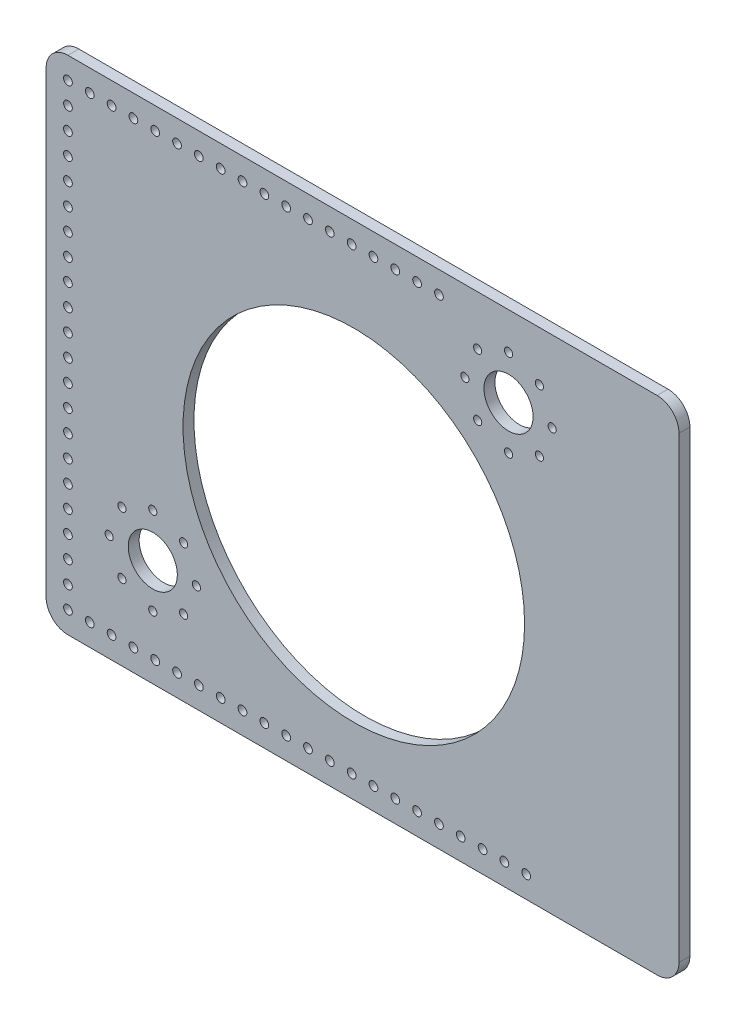
from build123d import *

# Parameters (mm, degrees)
SKETCH1_W           = 368.3
SKETCH1_H           = 292.1
SKETCH1_R           = 99.3775
SKETCH1_R_2         = 2.54
BOSS_EXTRUDE1_DEPTH = 6.35
SKETCH2_R           = 14.2875
SKETCH2_R_2         = 2.38125
CUT_EXTRUDE1_DEPTH  = 7.35
FILLET1_R           = 12.7


with BuildPart() as part:
    # Sketch1 → Boss-Extrude1 (new body)
    with BuildSketch(Plane.XY):
        with Locations((184.15, 146.05)):
            Rectangle(SKETCH1_W, SKETCH1_H)
        with Locations((179.07, 138.43)):
            Circle(SKETCH1_R, mode=Mode.SUBTRACT)
        with Locations((12.7, 279.4)):
            Circle(SKETCH1_R_2, mode=Mode.SUBTRACT)
        with Locations((25.4, 279.4)):
            Circle(SKETCH1_R_2, mode=Mode.SUBTRACT)
        with Locations((38.1, 279.4)):
            Circle(SKETCH1_R_2, mode=Mode.SUBTRACT)
        with Locations((50.8, 279.4)):
            Circle(SKETCH1_R_2, mode=Mode.SUBTRACT)
        with Locations((63.5, 279.4)):
            Circle(SKETCH1_R_2, mode=Mode.SUBTRACT)
        with Locations((76.2, 279.4)):
            Circle(SKETCH1_R_2, mode=Mode.SUBTRACT)
        with Locations((88.9, 279.4)):
            Circle(SKETCH1_R_2, mode=Mode.SUBTRACT)
        with Locations((101.6, 279.4)):
            Circle(SKETCH1_R_2, mode=Mode.SUBTRACT)
        with Locations((114.3, 279.4)):
            Circle(SKETCH1_R_2, mode=Mode.SUBTRACT)
        with Locations((127, 279.4)):
            Circle(SKETCH1_R_2, mode=Mode.SUBTRACT)
        with Locations((139.7, 279.4)):
            Circle(SKETCH1_R_2, mode=Mode.SUBTRACT)
        with Locations((152.4, 279.4)):
            Circle(SKETCH1_R_2, mode=Mode.SUBTRACT)
        with Locations((165.1, 279.4)):
            Circle(SKETCH1_R_2, mode=Mode.SUBTRACT)
        with Locations((177.8, 279.4)):
            Circle(SKETCH1_R_2, mode=Mode.SUBTRACT)
        with Locations((190.5, 279.4)):
            Circle(SKETCH1_R_2, mode=Mode.SUBTRACT)
        with Locations((203.2, 279.4)):
            Circle(SKETCH1_R_2, mode=Mode.SUBTRACT)
        with Locations((215.9, 279.4)):
            Circle(SKETCH1_R_2, mode=Mode.SUBTRACT)
        with Locations((228.6, 279.4)):
            Circle(SKETCH1_R_2, mode=Mode.SUBTRACT)
        with Locations((12.7, 266.7)):
            Circle(SKETCH1_R_2, mode=Mode.SUBTRACT)
        with Locations((12.7, 254)):
            Circle(SKETCH1_R_2, mode=Mode.SUBTRACT)
        with Locations((12.7, 241.3)):
            Circle(SKETCH1_R_2, mode=Mode.SUBTRACT)
        with Locations((12.7, 228.6)):
            Circle(SKETCH1_R_2, mode=Mode.SUBTRACT)
        with Locations((12.7, 215.9)):
            Circle(SKETCH1_R_2, mode=Mode.SUBTRACT)
        with Locations((12.7, 203.2)):
            Circle(SKETCH1_R_2, mode=Mode.SUBTRACT)
        with Locations((12.7, 190.5)):
            Circle(SKETCH1_R_2, mode=Mode.SUBTRACT)
        with Locations((12.7, 177.8)):
            Circle(SKETCH1_R_2, mode=Mode.SUBTRACT)
        with Locations((12.7, 165.1)):
            Circle(SKETCH1_R_2, mode=Mode.SUBTRACT)
        with Locations((12.7, 152.4)):
            Circle(SKETCH1_R_2, mode=Mode.SUBTRACT)
        with Locations((12.7, 139.7)):
            Circle(SKETCH1_R_2, mode=Mode.SUBTRACT)
        with Locations((12.7, 127)):
            Circle(SKETCH1_R_2, mode=Mode.SUBTRACT)
        with Locations((12.7, 114.3)):
            Circle(SKETCH1_R_2, mode=Mode.SUBTRACT)
        with Locations((12.7, 101.6)):
            Circle(SKETCH1_R_2, mode=Mode.SUBTRACT)
        with Locations((12.7, 88.9)):
            Circle(SKETCH1_R_2, mode=Mode.SUBTRACT)
        with Locations((12.7, 76.2)):
            Circle(SKETCH1_R_2, mode=Mode.SUBTRACT)
        with Locations((12.7, 63.5)):
            Circle(SKETCH1_R_2, mode=Mode.SUBTRACT)
        with Locations((12.7, 50.8)):
            Circle(SKETCH1_R_2, mode=Mode.SUBTRACT)
        with Locations((12.7, 38.1)):
            Circle(SKETCH1_R_2, mode=Mode.SUBTRACT)
        with Locations((12.7, 25.4)):
            Circle(SKETCH1_R_2, mode=Mode.SUBTRACT)
        with Locations((12.7, 12.7)):
            Circle(SKETCH1_R_2, mode=Mode.SUBTRACT)
        with Locations((25.4, 12.7)):
            Circle(SKETCH1_R_2, mode=Mode.SUBTRACT)
        with Locations((38.1, 12.7)):
            Circle(SKETCH1_R_2, mode=Mode.SUBTRACT)
        with Locations((50.8, 12.7)):
            Circle(SKETCH1_R_2, mode=Mode.SUBTRACT)
        with Locations((63.5, 12.7)):
            Circle(SKETCH1_R_2, mode=Mode.SUBTRACT)
        with Locations((76.2, 12.7)):
            Circle(SKETCH1_R_2, mode=Mode.SUBTRACT)
        with Locations((88.9, 12.7)):
            Circle(SKETCH1_R_2, mode=Mode.SUBTRACT)
        with Locations((101.6, 12.7)):
            Circle(SKETCH1_R_2, mode=Mode.SUBTRACT)
        with Locations((114.3, 12.7)):
            Circle(SKETCH1_R_2, mode=Mode.SUBTRACT)
        with Locations((127, 12.7)):
            Circle(SKETCH1_R_2, mode=Mode.SUBTRACT)
        with Locations((139.7, 12.7)):
            Circle(SKETCH1_R_2, mode=Mode.SUBTRACT)
        with Locations((152.4, 12.7)):
            Circle(SKETCH1_R_2, mode=Mode.SUBTRACT)
        with Locations((165.1, 12.7)):
            Circle(SKETCH1_R_2, mode=Mode.SUBTRACT)
        with Locations((177.8, 12.7)):
            Circle(SKETCH1_R_2, mode=Mode.SUBTRACT)
        with Locations((190.5, 12.7)):
            Circle(SKETCH1_R_2, mode=Mode.SUBTRACT)
        with Locations((203.2, 12.7)):
            Circle(SKETCH1_R_2, mode=Mode.SUBTRACT)
        with Locations((215.9, 12.7)):
            Circle(SKETCH1_R_2, mode=Mode.SUBTRACT)
        with Locations((228.6, 12.7)):
            Circle(SKETCH1_R_2, mode=Mode.SUBTRACT)
        with Locations((241.3, 12.7)):
            Circle(SKETCH1_R_2, mode=Mode.SUBTRACT)
        with Locations((254, 12.7)):
            Circle(SKETCH1_R_2, mode=Mode.SUBTRACT)
        with Locations((266.7, 12.7)):
            Circle(SKETCH1_R_2, mode=Mode.SUBTRACT)
        with Locations((279.4, 12.7)):
            Circle(SKETCH1_R_2, mode=Mode.SUBTRACT)
    extrude(amount=BOSS_EXTRUDE1_DEPTH)

    # Sketch2 → Cut-Extrude1 (cut, through all)
    with BuildSketch(Plane.XY.offset(6.35)):
        with Locations((62.079722251, 62.079722251)):
            Circle(SKETCH2_R)
        with Locations((269.10870269, 245.243491741)):
            Circle(SKETCH2_R)
        with Locations((62.079722251, 87.479722251)):
            Circle(SKETCH2_R_2)
        with Locations((80.040234493, 80.040234493)):
            Circle(SKETCH2_R_2)
        with Locations((87.479722251, 62.079722251)):
            Circle(SKETCH2_R_2)
        with Locations((80.040234493, 44.119210009)):
            Circle(SKETCH2_R_2)
        with Locations((62.079722251, 36.679722251)):
            Circle(SKETCH2_R_2)
        with Locations((44.119210009, 44.119210009)):
            Circle(SKETCH2_R_2)
        with Locations((36.679722251, 62.079722251)):
            Circle(SKETCH2_R_2)
        with Locations((44.119210009, 80.040234493)):
            Circle(SKETCH2_R_2)
        with Locations((269.10870269, 270.643491741)):
            Circle(SKETCH2_R_2)
        with Locations((287.069214932, 263.204003983)):
            Circle(SKETCH2_R_2)
        with Locations((294.50870269, 245.243491741)):
            Circle(SKETCH2_R_2)
        with Locations((287.069214932, 227.282979499)):
            Circle(SKETCH2_R_2)
        with Locations((269.10870269, 219.843491741)):
            Circle(SKETCH2_R_2)
        with Locations((251.148190448, 227.282979499)):
            Circle(SKETCH2_R_2)
        with Locations((243.70870269, 245.243491741)):
            Circle(SKETCH2_R_2)
        with Locations((251.148190448, 263.204003983)):
            Circle(SKETCH2_R_2)
    extrude(amount=-CUT_EXTRUDE1_DEPTH, mode=Mode.SUBTRACT)

    # Fillet1
    fillet1_edges = [part.edges().sort_by_distance(p)[0] for p in [
        (0, 292.1, 3.175),
        (368.3, 292.1, 3.175),
        (368.3, 0, 3.175),
        (0, 0, 3.175),
    ]]
    fillet(fillet1_edges, radius=FILLET1_R)


solid = part.part
